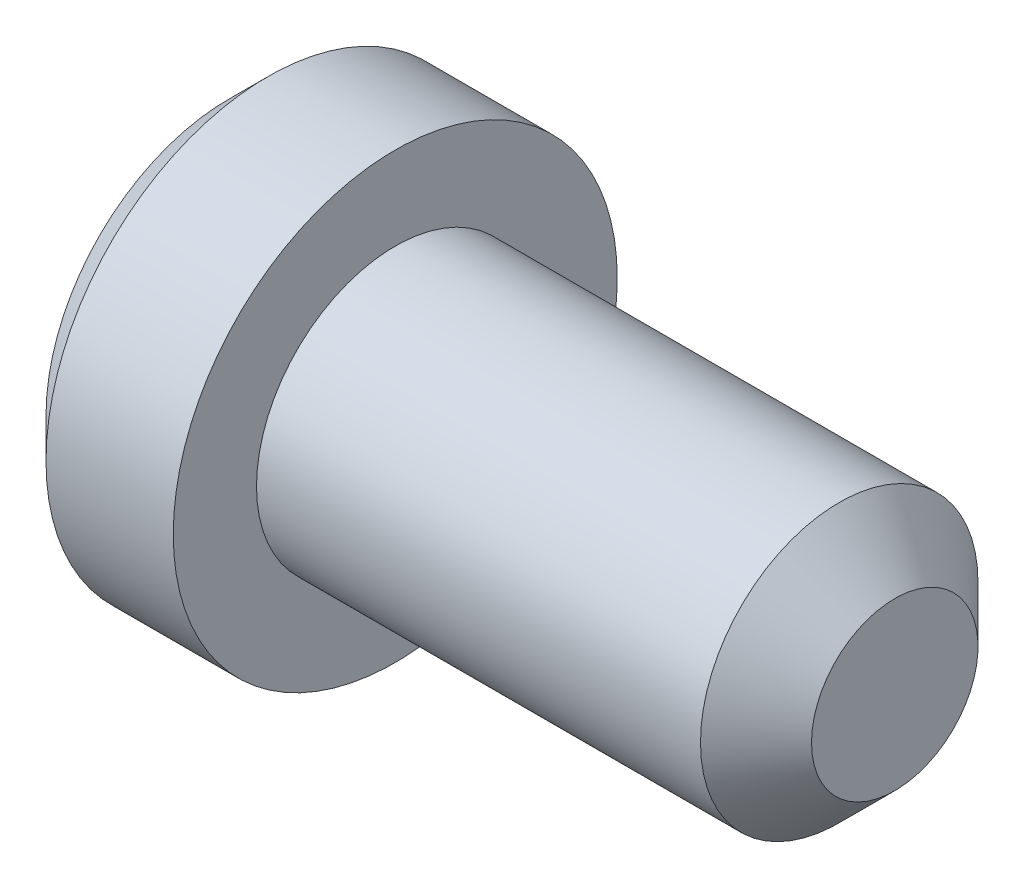
from build123d import *


with BuildPart() as part:
    # Sketch1 → Revolve1 (revolve)
    with BuildSketch(Plane.XY):
        Polygon((-30, 0), (-30, -32.928932188), (-22.928932188, -40), (0, -40), (0, -25), (80, -25), (90, -15), (90, 0), align=None)
    revolve(axis=Axis((-137.625060789, 0, 0), (1, 0, 0)))


solid = part.part
